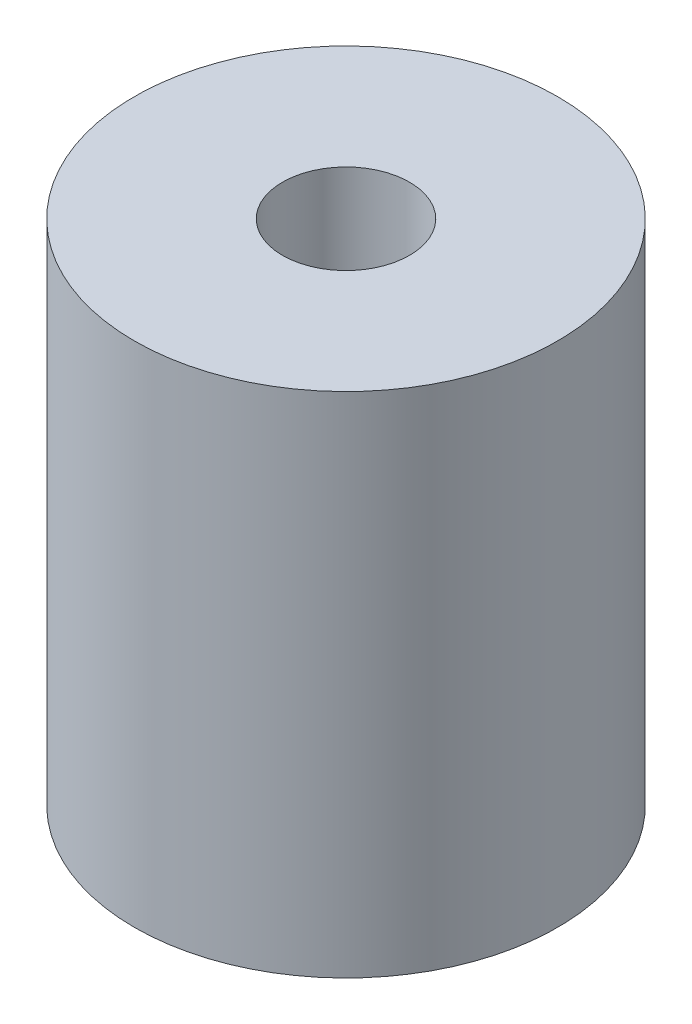
from build123d import *

# Parameters (mm, degrees)
CROQUIS1_R              = 5
SALIENTE_EXTRUIR1_DEPTH = 12
CROQUIS2_R              = 1.5
CORTAR_EXTRUIR1_DEPTH   = 5
CROQUIS4_R              = 1.5
CORTAR_EXTRUIR2_DEPTH   = 5


with BuildPart() as part:
    # Croquis1 → Saliente-Extruir1 (new body)
    with BuildSketch(Plane(origin=(0, 0, 0), x_dir=(1, 0, 0), z_dir=(0, 1, 0))):
        Circle(CROQUIS1_R)
    extrude(amount=SALIENTE_EXTRUIR1_DEPTH)

    # Croquis2 → Cortar-Extruir1 (cut)
    with BuildSketch(Plane(origin=(0, 12, 0), x_dir=(1, 0, 0), z_dir=(0, 1, 0))):
        Circle(CROQUIS2_R)
    extrude(amount=-CORTAR_EXTRUIR1_DEPTH, mode=Mode.SUBTRACT)

    # Croquis4 → Cortar-Extruir2 (cut)
    with BuildSketch(Plane.XZ):
        Circle(CROQUIS4_R)
    extrude(amount=-CORTAR_EXTRUIR2_DEPTH, mode=Mode.SUBTRACT)


solid = part.part
